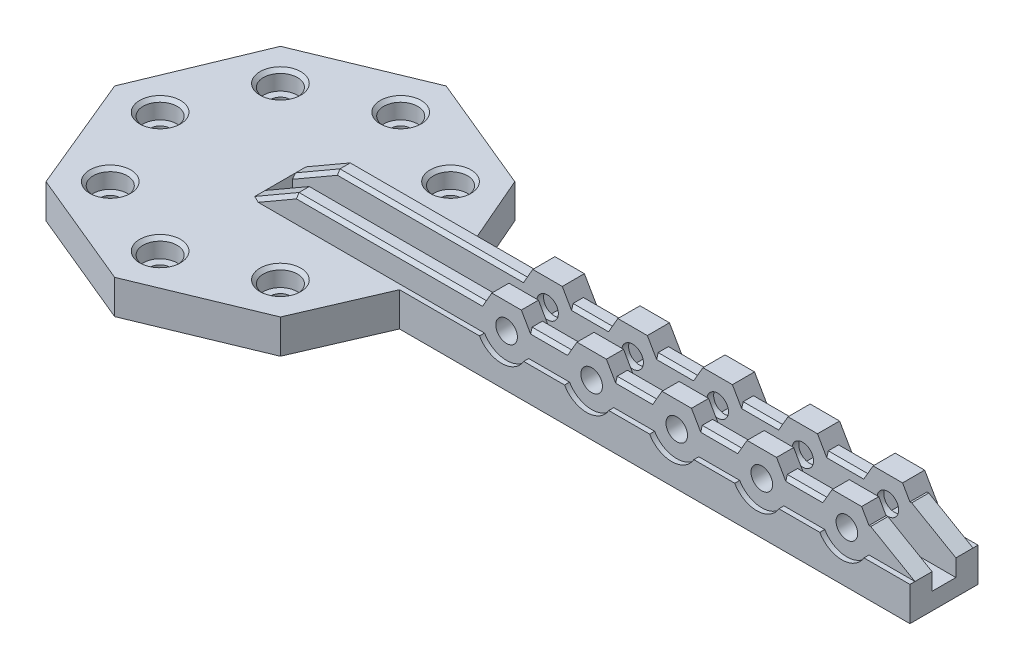
from build123d import *

# Parameters (mm, degrees)
BOSS_EXTRUDE1_DEPTH = 10
SKETCH2_R           = 2.85
CUT_EXTRUDE1_DEPTH  = 14
SKETCH5_R           = 5
CUT_EXTRUDE2_DEPTH  = 5.5
BOSS_EXTRUDE3_DEPTH = 10
SKETCH8_W           = 195
SKETCH8_H           = 5.03
BOSS_EXTRUDE4_DEPTH = 7.5
BOSS_EXTRUDE5_START = -5.03
BOSS_EXTRUDE5_DEPTH = 6.5
CUT_EXTRUDE3_DEPTH  = 17.06
SKETCH10_W          = 195
SKETCH10_H          = 7
CUT_EXTRUDE4_DEPTH  = 5
SKETCH11_R          = 3.175
CUT_EXTRUDE5_DEPTH  = 23
SKETCH12_R          = 7.5
CUT_EXTRUDE6_DEPTH  = 1.47
SKETCH14_W          = 7.794228634
SKETCH14_H          = 5.03
BOSS_EXTRUDE6_DEPTH = 1.5
CUT_EXTRUDE7_DEPTH  = 4.5
BOSS_EXTRUDE7_DEPTH = 5.03
LPATTERN4_COUNT     = 5
LPATTERN4_PITCH     = 25
CHAMFER1_SIZE       = 1
CHAMFER2_SIZE       = 1


with BuildPart() as part:
    # Sketch1 → Boss-Extrude1 (new body)
    with BuildSketch(Plane(origin=(0, 0, 0), x_dir=(1, 0, 0), z_dir=(0, 1, 0))):
        Polygon((48.707649013, 0), (34.441508913, 34.441508913), (0, 48.707649013), (-34.441508913, 34.441508913), (-48.707649013, 0), (-34.441508913, -34.441508913), (0, -48.707649013), (34.441508913, -34.441508913), align=None)
    extrude(amount=-BOSS_EXTRUDE1_DEPTH)

    # Sketch2 → Cut-Extrude1 (cut)
    with BuildSketch(Plane(origin=(0, 0, 0), x_dir=(1, 0, 0), z_dir=(0, 1, 0))):
        with Locations((-35.355339059, 0)):
            Circle(SKETCH2_R)
        with Locations((-25, 25)):
            Circle(SKETCH2_R)
        with Locations((0, 35.355339059)):
            Circle(SKETCH2_R)
        with Locations((25, 25)):
            Circle(SKETCH2_R)
        with Locations((25, -25)):
            Circle(SKETCH2_R)
        with Locations((0, -35.355339059)):
            Circle(SKETCH2_R)
        with Locations((-25, -25)):
            Circle(SKETCH2_R)
    extrude(amount=-CUT_EXTRUDE1_DEPTH, mode=Mode.SUBTRACT)

    # Sketch5 → Cut-Extrude2 (cut)
    with BuildSketch(Plane(origin=(0, 0, 0), x_dir=(1, 0, 0), z_dir=(0, 1, 0))):
        with Locations((-35.355339059, 0)):
            Circle(SKETCH5_R)
        with Locations((-25, 25)):
            Circle(SKETCH5_R)
        with Locations((0, 35.355339059)):
            Circle(SKETCH5_R)
        with Locations((25, 25)):
            Circle(SKETCH5_R)
        with Locations((25, -25)):
            Circle(SKETCH5_R)
        with Locations((0, -35.355339059)):
            Circle(SKETCH5_R)
        with Locations((-25, -25)):
            Circle(SKETCH5_R)
    extrude(amount=-CUT_EXTRUDE2_DEPTH, mode=Mode.SUBTRACT)

    # Sketch7 → Boss-Extrude3 (add)
    with BuildSketch(Plane(origin=(0, 0, 0), x_dir=(1, 0, 0), z_dir=(0, 1, 0))):
        Polygon((45, -10), (34.441508913, -34.441508913), (34.441508913, 34.441508913), (45, 10), (195, 10), (195, -10), align=None)
    extrude(amount=-BOSS_EXTRUDE3_DEPTH)

    # Sketch8 → Boss-Extrude4 (add)
    with BuildSketch(Plane(origin=(0, 0, 0), x_dir=(1, 0, 0), z_dir=(0, 1, 0))):
        with Locations((97.5, -6.015)):
            Rectangle(SKETCH8_W, SKETCH8_H)
        with Locations((97.5, 6.015)):
            Rectangle(SKETCH8_W, SKETCH8_H)
    extrude(amount=BOSS_EXTRUDE4_DEPTH)

    # Sketch13 → Boss-Extrude5 (add)
    with BuildSketch(Plane(origin=(0, 0, -8.53), x_dir=(-1, 0, 0), z_dir=(0, 0, -1)).offset(BOSS_EXTRUDE5_START)):
        Polygon((-166.339745962, 3.75), (-170.669872981, 11.25), (-179.330127019, 11.25), (-183.660254038, 3.75), (-183.660254038, -3.75), (-166.339745962, -3.75), align=None)
        Polygon((-168.937822174, 3.75), (-171.968911087, 9), (-178.031088913, 9), (-181.062177826, 3.75), (-178.031088913, -1.5), (-171.968911087, -1.5), align=None, mode=Mode.SUBTRACT)
    boss_extrude5 = extrude(amount=BOSS_EXTRUDE5_DEPTH)

    # Sketch9 → Cut-Extrude3 (cut)
    with BuildSketch(Plane.XY.offset(8.53)):
        Polygon((0, 0), (12.990381057, 7.5), (0, 7.5), align=None)
        Polygon((182.009618943, 7.5), (195, 0), (195, 7.5), align=None)
    extrude(amount=-CUT_EXTRUDE3_DEPTH, mode=Mode.SUBTRACT)

    # Sketch10 → Cut-Extrude4 (cut)
    with BuildSketch(Plane(origin=(0, 0, 0), x_dir=(1, 0, 0), z_dir=(0, 1, 0))):
        with Locations((97.5, 0)):
            Rectangle(SKETCH10_W, SKETCH10_H)
    extrude(amount=-CUT_EXTRUDE4_DEPTH, mode=Mode.SUBTRACT)

    # Sketch11 → Cut-Extrude5 (cut)
    with BuildSketch(Plane.XY.offset(8.53)):
        with Locations((175, 3.75)):
            Circle(SKETCH11_R)
    cut_extrude5 = extrude(amount=-CUT_EXTRUDE5_DEPTH, mode=Mode.SUBTRACT)

    # Sketch12 → Cut-Extrude6 (cut)
    with BuildSketch(Plane.XY.offset(10)):
        with Locations((175, 3.75)):
            Circle(SKETCH12_R)
    cut_extrude6 = extrude(amount=-CUT_EXTRUDE6_DEPTH, mode=Mode.SUBTRACT)

    # Sketch14 → Boss-Extrude6 (add)
    with BuildSketch(Plane(origin=(0, 7.5, 0), x_dir=(1, 0, 0), z_dir=(0, 1, 0))):
        with Locations((175, 6.015)):
            Rectangle(SKETCH14_W, SKETCH14_H)
    boss_extrude6 = extrude(amount=BOSS_EXTRUDE6_DEPTH)

    # Sketch15 → Cut-Extrude7 (cut)
    with BuildSketch(Plane(origin=(0, 0, -10), x_dir=(-1, 0, 0), z_dir=(0, 0, -1))):
        Polygon((-168.937822174, 3.75), (-171.968911087, 9), (-178.031088913, 9), (-181.062177826, 3.75), (-178.031088913, -1.5), (-171.968911087, -1.5), align=None)
    cut_extrude7 = extrude(amount=-CUT_EXTRUDE7_DEPTH, mode=Mode.SUBTRACT)

    # Sketch16 → Boss-Extrude7 (add)
    with BuildSketch(Plane.XY.offset(8.53)):
        Polygon((168.504809472, 7.5), (170.669872981, 11.25), (179.330127019, 11.25), (181.495190528, 7.5), align=None)
    boss_extrude7 = extrude(amount=-BOSS_EXTRUDE7_DEPTH)

    # LPattern4: Boss-Extrude5, Cut-Extrude5, Cut-Extrude6, Boss-Extrude6, Cut-Extrude7, Boss-Extrude7 ×5
    with Locations(*[(-i * LPATTERN4_PITCH, 0, 0) for i in range(1, LPATTERN4_COUNT)]):
        add(boss_extrude5)
        add(cut_extrude5, mode=Mode.SUBTRACT)
        add(cut_extrude6, mode=Mode.SUBTRACT)
        add(boss_extrude6)
        add(cut_extrude7, mode=Mode.SUBTRACT)
        add(boss_extrude7)

    # Chamfer1
    chamfer1_edges = [part.edges().sort_by_distance(p)[0] for p in [
        (-40.355339059, 0, 0),
        (-30, 0, 25),
        (-5, 0, 35.355339059),
        (20, 0, 25),
        (20, 0, -25),
        (-5, 0, -35.355339059),
        (-30, 0, -25),
    ]]
    chamfer(chamfer1_edges, length=CHAMFER1_SIZE)

    # Chamfer2
    chamfer2_edges = [part.edges().sort_by_distance(p)[0] for p in [
        (162.5, 7.5, -8.53),
        (40.747595264, 7.5, -3.5),
        (6.495190528, 3.75, -3.5),
        (40.747595264, 7.5, 8.53),
        (6.495190528, 3.75, 3.5),
        (6.495190528, 3.75, 8.53),
        (6.495190528, 3.75, -8.53),
        (162.5, 7.5, 3.5),
        (162.5, 7.5, -3.5),
        (137.5, 7.5, -8.53),
        (137.5, 7.5, -3.5),
        (112.5, 7.5, -8.53),
        (112.5, 7.5, -3.5),
        (87.5, 7.5, -8.53),
        (87.5, 7.5, -3.5),
        (40.747595264, 7.5, -8.53),
        (137.5, 7.5, 3.5),
        (162.5, 7.5, 8.53),
        (112.5, 7.5, 3.5),
        (137.5, 7.5, 8.53),
        (87.5, 7.5, 3.5),
        (112.5, 7.5, 8.53),
        (40.747595264, 7.5, 3.5),
        (87.5, 7.5, 8.53),
    ]]
    chamfer(chamfer2_edges, length=CHAMFER2_SIZE)


solid = part.part
